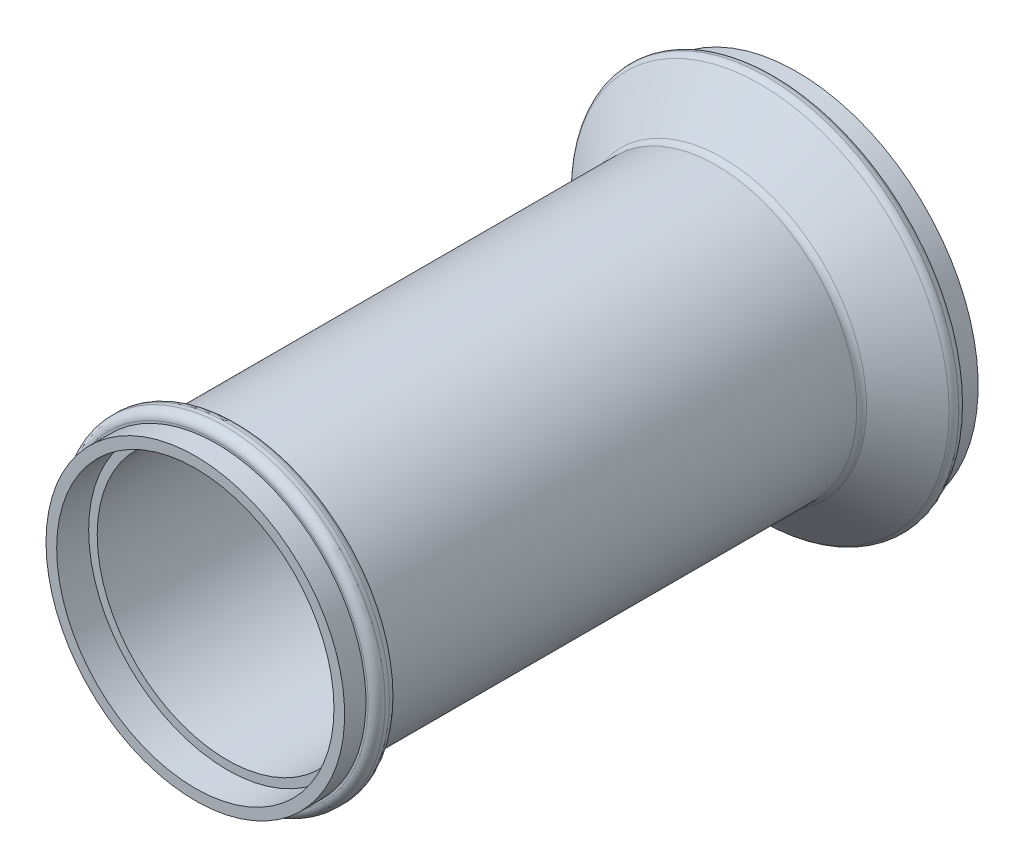
from build123d import *

# Parameters (mm, degrees)
FILLET1_R = 2


with BuildPart() as part:
    # Sketch1 → Revolve1 (revolve)
    with BuildSketch(Plane(origin=(0, 0, 0), x_dir=(1, 0, 0), z_dir=(0, 1, 0))):
        Polygon((0, 0), (0, -141), (35, -141), (35, -136), (37.5, -136), (37.5, -131), (33, -131), (33, -18), (45, -8), (45, -5), (42.5, -5), (42.5, 0), align=None)
    revolve(axis=Axis((0, 0, 0), (0, 0, 1)))

    # Fillet1
    fillet1_edges = [part.edges().sort_by_distance(p)[0] for p in [
        (-37.5, 0, 136),
        (-37.5, 0, 131),
        (-33, 0, 131),
        (-33, 0, 18),
        (-45, 0, 8),
        (-45, 0, 5),
    ]]
    fillet(fillet1_edges, radius=FILLET1_R)

    # Sketch2 → Cut-Revolve1 (revolve, cut)
    with BuildSketch(Plane(origin=(0, 0, 0), x_dir=(1, 0, 0), z_dir=(0, 1, 0))):
        Polygon((40, 0), (40, -8.912395968), (30.5, -16.829062635), (30.5, -133.5), (32.5, -133.5), (32.5, -141), (0, -141), (0, 0), align=None)
    revolve(axis=Axis((0, 0, 0), (0, 0, 1)), mode=Mode.SUBTRACT)


solid = part.part
